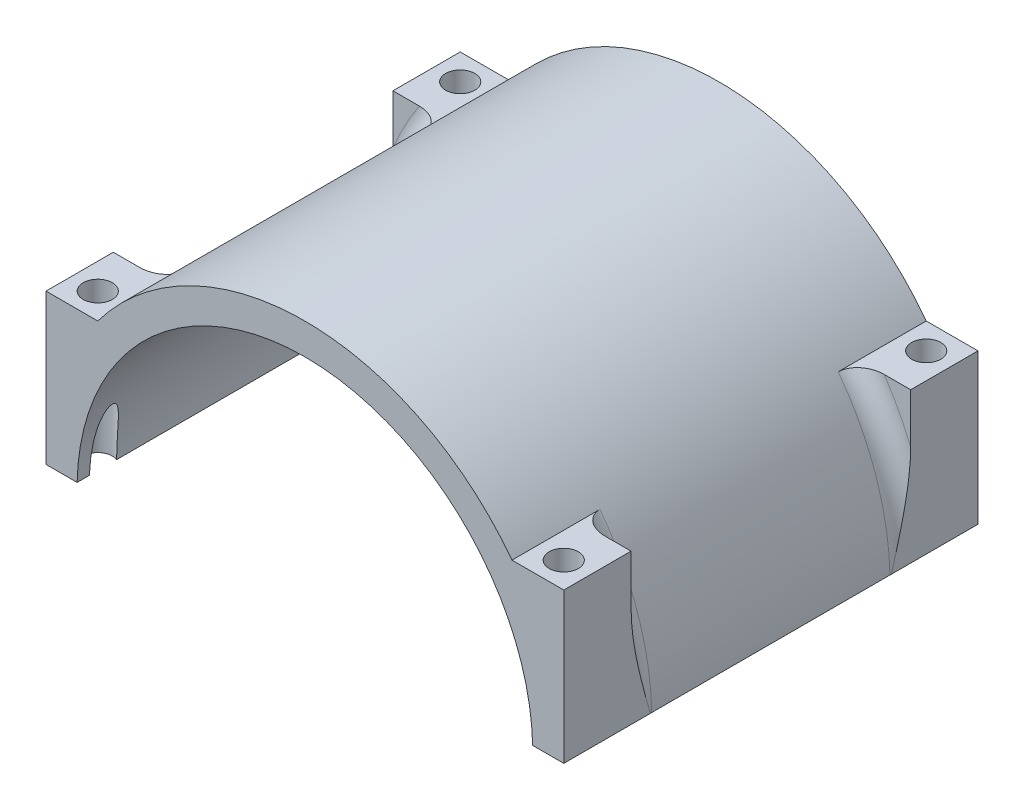
from build123d import *

# Parameters (mm, degrees)
BOSS_EXTRUDE1_DEPTH     = 50.8
BOSS_EXTRUDE2_DEPTH     = 16.51
SKETCH4_W               = 127
SKETCH4_H               = 1.27
CUT_EXTRUDE1_DEPTH      = 102.6
F_1_4_CLEARANCE_HOLE1_D = 7.14248
FILLET1_R               = 5.08


with BuildPart() as part:
    # Sketch1 → Boss-Extrude1 (new body, symmetric)
    with BuildSketch(Plane.XY):
        with BuildLine():
            Line((55.88, 0), (63.5, 0))
            ThreePointArc((63.5, 0), (0, 63.5), (-63.5, 0))
            Line((-63.5, 0), (-55.88, 0))
            ThreePointArc((-55.88, 0), (0, 55.88), (55.88, 0))
        make_face()
    extrude(amount=BOSS_EXTRUDE1_DEPTH, both=True)

    # Sketch2 → Boss-Extrude2 (add)
    with BuildSketch(Plane(origin=(0, 0, -50.8), x_dir=(-1, 0, 0), z_dir=(0, 0, -1))):
        with BuildLine():
            Line((-63.5, 38.1), (-63.5, 0))
            ThreePointArc((-63.5, 0), (-60.241389426, 20.080463142), (-50.8, 38.1))
            Line((-50.8, 38.1), (-63.5, 38.1))
        make_face()
        with BuildLine():
            Line((63.5, 38.1), (50.8, 38.1))
            ThreePointArc((50.8, 38.1), (60.241389426, 20.080463142), (63.5, 0))
            Line((63.5, 0), (63.5, 38.1))
        make_face()
    boss_extrude2 = extrude(amount=-BOSS_EXTRUDE2_DEPTH)

    # Mirror1: Boss-Extrude2 across plane
    add(boss_extrude2.mirror(Plane.XY))

    # Sketch4 → Cut-Extrude1 (cut, through all)
    with BuildSketch(Plane.XY.offset(50.8)):
        with Locations((0, 0.635)):
            Rectangle(SKETCH4_W, SKETCH4_H)
    extrude(amount=-CUT_EXTRUDE1_DEPTH, mode=Mode.SUBTRACT)

    # 1/4 Clearance Hole1 (through all)
    with Locations(Plane(origin=(-57.15, 38.1, -44.45), x_dir=(0, 0, 1), z_dir=(0, 1, 0))):
        with Locations((0, 0), (0, 114.3), (88.9, 0), (88.9, 114.3)):
            Hole(F_1_4_CLEARANCE_HOLE1_D / 2)

    # Fillet1
    fillet1_edges = [part.edges().sort_by_distance(p)[0] for p in [
        (60.037562307, 20.681903014, 34.29),
        (-60.037562307, 20.681903014, 34.29),
        (-60.037562307, 20.681903014, -34.29),
        (60.037562307, 20.681903014, -34.29),
    ]]
    fillet(fillet1_edges, radius=FILLET1_R)


solid = part.part
